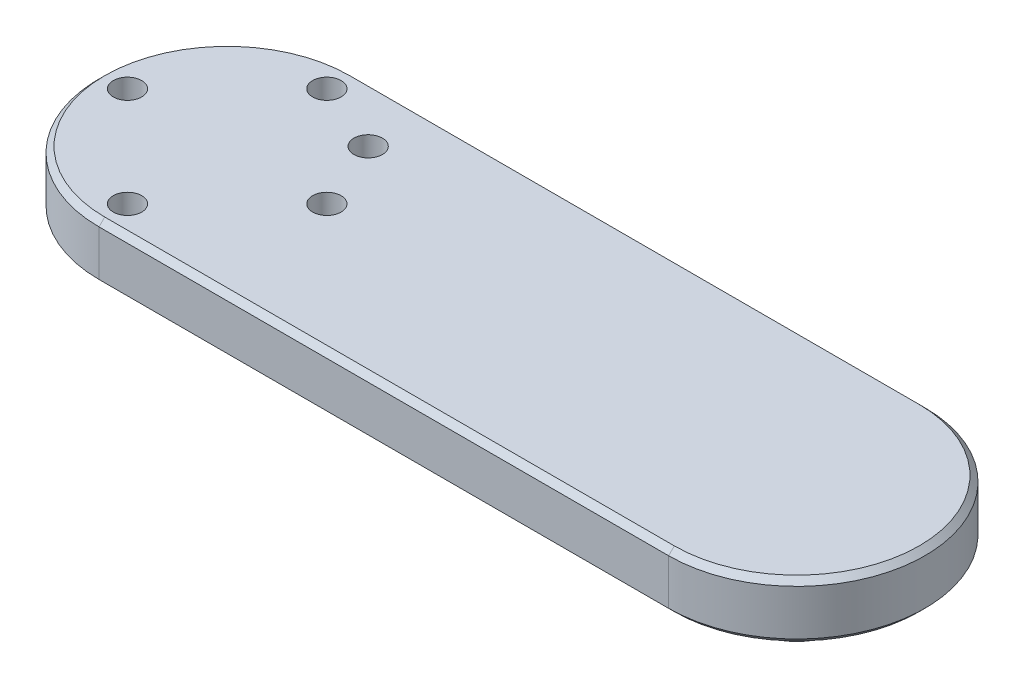
from build123d import *

# Parameters (mm, degrees)
BOSS_EXTRUDE1_DEPTH = 20
SKETCH2_R           = 5
CUT_EXTRUDE1_DEPTH  = 21
SKETCH3_R           = 15
BOSS_EXTRUDE2_DEPTH = 20
CHAMFER1_SIZE       = 2


with BuildPart() as part:
    # Sketch1 → Boss-Extrude1 (new body)
    with BuildSketch(Plane(origin=(0, 0, 0), x_dir=(1, 0, 0), z_dir=(0, 1, 0))):
        with BuildLine():
            Line((-100, 45), (100, 45))
            ThreePointArc((100, 45), (145, 0), (100, -45))
            Line((100, -45), (-100, -45))
            ThreePointArc((-100, -45), (-145, 0), (-100, 45))
        make_face()
    extrude(amount=BOSS_EXTRUDE1_DEPTH)

    # Sketch2 → Cut-Extrude1 (cut, through all)
    with BuildSketch(Plane(origin=(0, 20, 0), x_dir=(1, 0, 0), z_dir=(0, 1, 0))):
        with Locations((-135, 0)):
            Circle(SKETCH2_R)
        with Locations((-100, 35)):
            Circle(SKETCH2_R)
        with Locations((-65, 0)):
            Circle(SKETCH2_R)
        with Locations((-100, -35)):
            Circle(SKETCH2_R)
        with Locations((-75.251262658, 24.748737342)):
            Circle(SKETCH2_R)
    extrude(amount=-CUT_EXTRUDE1_DEPTH, mode=Mode.SUBTRACT)

    # Sketch3 → Boss-Extrude2 (add)
    with BuildSketch(Plane.XZ):
        with Locations((100, 0)):
            Circle(SKETCH3_R)
    extrude(amount=BOSS_EXTRUDE2_DEPTH)

    # Chamfer1
    chamfer1_edges = [part.edges().sort_by_distance(p)[0] for p in [
        (145, 20, 0),
        (0, 20, -45),
        (-145, 20, 0),
        (0, 0, -45),
        (145, 0, 0),
        (0, 0, 45),
        (-145, 0, 0),
        (0, 20, 45),
    ]]
    chamfer(chamfer1_edges, length=CHAMFER1_SIZE)


solid = part.part
